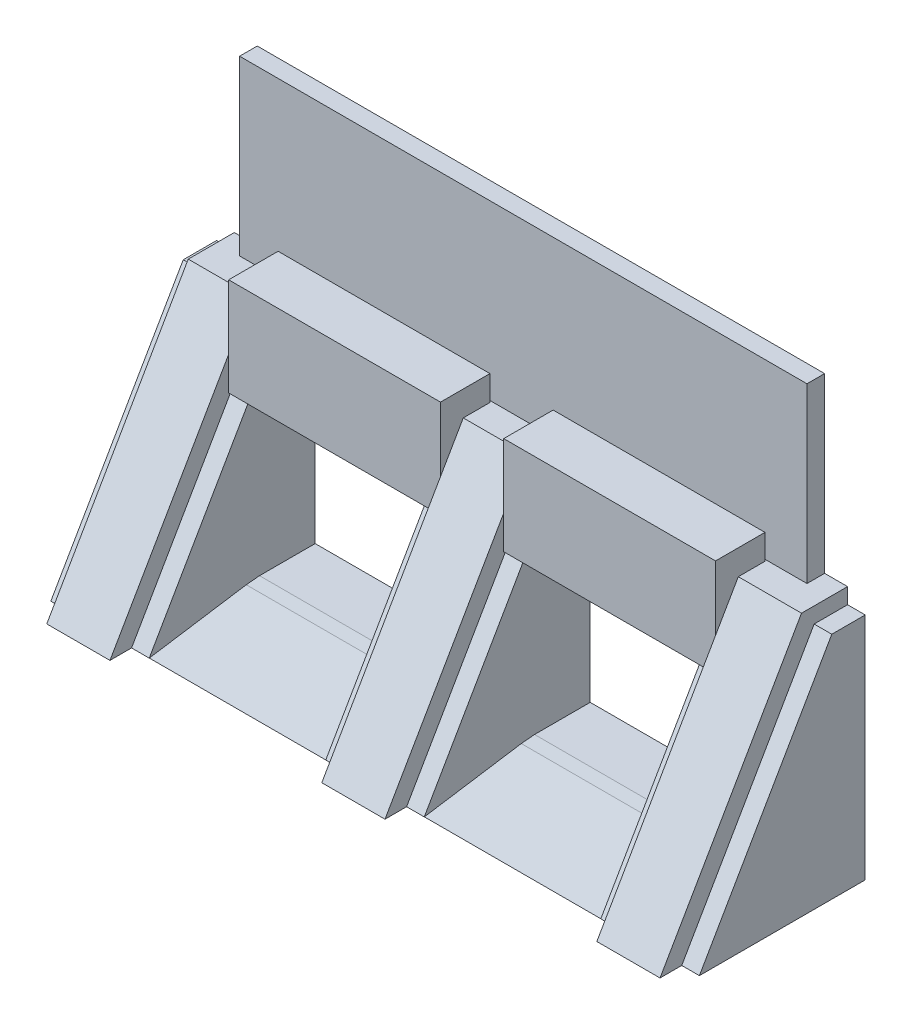
from build123d import *

# Parameters (mm, degrees)
SKETCH_1_W           = 3674
SKETCH_1_H           = 1912.4
EXTRUDE_1_DEPTH      = 1389
CUT_EXTRUDE_1_DEPTH  = 3675
CUT_EXTRUDE_3_DEPTH  = 100
CUT_EXTRUDE_START    = -3674
CUT_EXTRUDE_4_DEPTH  = 100
SKETCH_6_W           = 3214
SKETCH_6_H           = 950
EXTRUDE_2_DEPTH      = 980
SKETCH_7_W           = 100
SKETCH_7_H           = 1603.589364395
CUT_EXTRUDE_5_DEPTH  = 106
SKETCH_8_W           = 1000
SKETCH_8_H           = 1389
CUT_EXTRUDE_6_DEPTH  = 1913.4
SKETCH_9_W           = 100
SKETCH_9_H           = 1603.589364395
CUT_EXTRUDE_7_DEPTH  = 106
SKETCH_11_W          = 100
SKETCH_11_H          = 1603.589364395
CUT_EXTRUDE_8_DEPTH  = 106
SKETCH_14_W          = 1000
SKETCH_14_H          = 1389
CUT_EXTRUDE_9_DEPTH  = 1913.4
SKETCH_16_W          = 100
SKETCH_16_H          = 1603.589364395
CUT_EXTRUDE_10_DEPTH = 106
SKETCH_18_W          = 1200
SKETCH_18_H          = 555
CUT_EXTRUDE_11_DEPTH = 953.4
SKETCH_18_2_W        = 1200
SKETCH_18_2_H        = 555
EXTRUDE_3_DEPTH      = 280
EXTRUDE_4_DEPTH      = 1000
EXTRUDE_START        = 1558
EXTRUDE_5_DEPTH      = 1000
SKETCH_23_W          = 3674
SKETCH_23_H          = 2369
CUT_EXTRUDE_12_DEPTH = 850


with BuildPart() as part:
    # 草图1 → 凸台-拉伸1 (new body)
    with BuildSketch(Plane(origin=(0, 0, 0), x_dir=(1, 0, 0), z_dir=(0, 1, 0))):
        Rectangle(SKETCH_1_W, SKETCH_1_H)
    extrude(amount=EXTRUDE_1_DEPTH)

    # 草图2 → 切除-拉伸1 (cut, through all)
    with BuildSketch(Plane.ZY.offset(1837)):
        Polygon((154.84, 1389), (956.2, 0), (956.2, 1389), align=None)
    extrude(amount=-CUT_EXTRUDE_1_DEPTH, mode=Mode.SUBTRACT)

    # 草图5 → 切除-拉伸3 (cut)
    with BuildSketch(Plane(origin=(1837, 0, 0), x_dir=(0, 0, -1), z_dir=(1, 0, 0))):
        Polygon((-154.84, 1389), (-956.2, 0), (-833.252958963, 0), (-83.24, 1300), (956.2, 1300), (956.2, 1389), align=None)
    extrude(amount=-CUT_EXTRUDE_3_DEPTH, mode=Mode.SUBTRACT)

    # 草图5<2> → 切除-拉伸4 (cut)
    with BuildSketch(Plane(origin=(1837, 0, 0), x_dir=(0, 0, -1), z_dir=(1, 0, 0)).offset(CUT_EXTRUDE_START)):
        Polygon((-154.84, 1389), (-956.2, 0), (-833.252958963, 0), (-83.24, 1300), (956.2, 1300), (956.2, 1389), align=None)
    extrude(amount=CUT_EXTRUDE_4_DEPTH, mode=Mode.SUBTRACT)

    # 草图6 → 凸台-拉伸2 (add)
    with BuildSketch(Plane(origin=(0, 1389, 0), x_dir=(1, 0, 0), z_dir=(0, 1, 0))):
        with Locations((0, 481.2)):
            Rectangle(SKETCH_6_W, SKETCH_6_H)
    extrude(amount=EXTRUDE_2_DEPTH)

    # 草图7 → 切除-拉伸5 (cut)
    with BuildSketch(Plane(origin=(0, 413.897031381, 717.409125222), x_dir=(1, 0, 0), z_dir=(0, 0.499728932, 0.866181849))):
        with Locations((-1329, 323.953877679)):
            Rectangle(SKETCH_7_W, SKETCH_7_H)
    extrude(amount=-CUT_EXTRUDE_5_DEPTH, mode=Mode.SUBTRACT)

    # 草图8 → 切除-拉伸6 (cut, through all)
    with BuildSketch(Plane.XY.offset(956.2)):
        with Locations((-779, 694.5)):
            Rectangle(SKETCH_8_W, SKETCH_8_H)
    extrude(amount=-CUT_EXTRUDE_6_DEPTH, mode=Mode.SUBTRACT)

    # 草图9 → 切除-拉伸7 (cut)
    with BuildSketch(Plane(origin=(0, 413.897031381, 717.409125222), x_dir=(1, 0, 0), z_dir=(0, 0.499728932, 0.866181849))):
        with Locations((-229, 323.953877679)):
            Rectangle(SKETCH_9_W, SKETCH_9_H)
    extrude(amount=-CUT_EXTRUDE_7_DEPTH, mode=Mode.SUBTRACT)

    # 草图11 → 切除-拉伸8 (cut)
    with BuildSketch(Plane(origin=(0, 413.897031381, 717.409125222), x_dir=(1, 0, 0), z_dir=(0, 0.499728932, 0.866181849))):
        with Locations((229, 323.953877679)):
            Rectangle(SKETCH_11_W, SKETCH_11_H)
    extrude(amount=-CUT_EXTRUDE_8_DEPTH, mode=Mode.SUBTRACT)

    # 草图14 → 切除-拉伸9 (cut, through all)
    with BuildSketch(Plane.XY.offset(956.2)):
        with Locations((779, 694.5)):
            Rectangle(SKETCH_14_W, SKETCH_14_H)
    extrude(amount=-CUT_EXTRUDE_9_DEPTH, mode=Mode.SUBTRACT)

    # 草图16 → 切除-拉伸10 (cut)
    with BuildSketch(Plane(origin=(0, 413.897031381, 717.409125222), x_dir=(1, 0, 0), z_dir=(0, 0.499728932, 0.866181849))):
        with Locations((1329, 323.953877679)):
            Rectangle(SKETCH_16_W, SKETCH_16_H)
    extrude(amount=-CUT_EXTRUDE_10_DEPTH, mode=Mode.SUBTRACT)

    # 草图18 → 切除-拉伸11 (cut, through all)
    with BuildSketch(Plane.XY.offset(3.8)):
        with Locations((-779, 1253.5)):
            Rectangle(SKETCH_18_W, SKETCH_18_H)
        with Locations((779, 1253.5)):
            Rectangle(SKETCH_18_W, SKETCH_18_H)
    extrude(amount=CUT_EXTRUDE_11_DEPTH, mode=Mode.SUBTRACT)

    # 草图18<2> → 凸台-拉伸3 (add)
    with BuildSketch(Plane.XY.offset(3.8)):
        with Locations((-779, 1253.5)):
            Rectangle(SKETCH_18_2_W, SKETCH_18_2_H)
        with Locations((779, 1253.5)):
            Rectangle(SKETCH_18_2_W, SKETCH_18_2_H)
    extrude(amount=EXTRUDE_3_DEPTH)

    # 草图21 → 凸台-拉伸4 (add)
    with BuildSketch(Plane(origin=(-1279, 0, 0), x_dir=(0, 0, -1), z_dir=(1, 0, 0))):
        Polygon((-833.252958963, 0), (-284.1184014, 85.038227225), (-209.1184014, 92.02), (956.2, 92.02), (956.2, 0), align=None)
    extrude(amount=EXTRUDE_4_DEPTH)

    # 草图21<2> → 凸台-拉伸5 (add)
    with BuildSketch(Plane(origin=(-1279, 0, 0), x_dir=(0, 0, -1), z_dir=(1, 0, 0)).offset(EXTRUDE_START)):
        Polygon((-833.252958963, 0), (-284.1184014, 85.038227225), (-209.1184014, 92.02), (956.2, 92.02), (956.2, 0), align=None)
    extrude(amount=EXTRUDE_5_DEPTH)

    # 草图23 → 切除-拉伸12 (cut)
    with BuildSketch(Plane(origin=(0, 0, -956.2), x_dir=(-1, 0, 0), z_dir=(0, 0, -1))):
        with Locations((0, 1184.5)):
            Rectangle(SKETCH_23_W, SKETCH_23_H)
    extrude(amount=-CUT_EXTRUDE_12_DEPTH, mode=Mode.SUBTRACT)


solid = part.part
